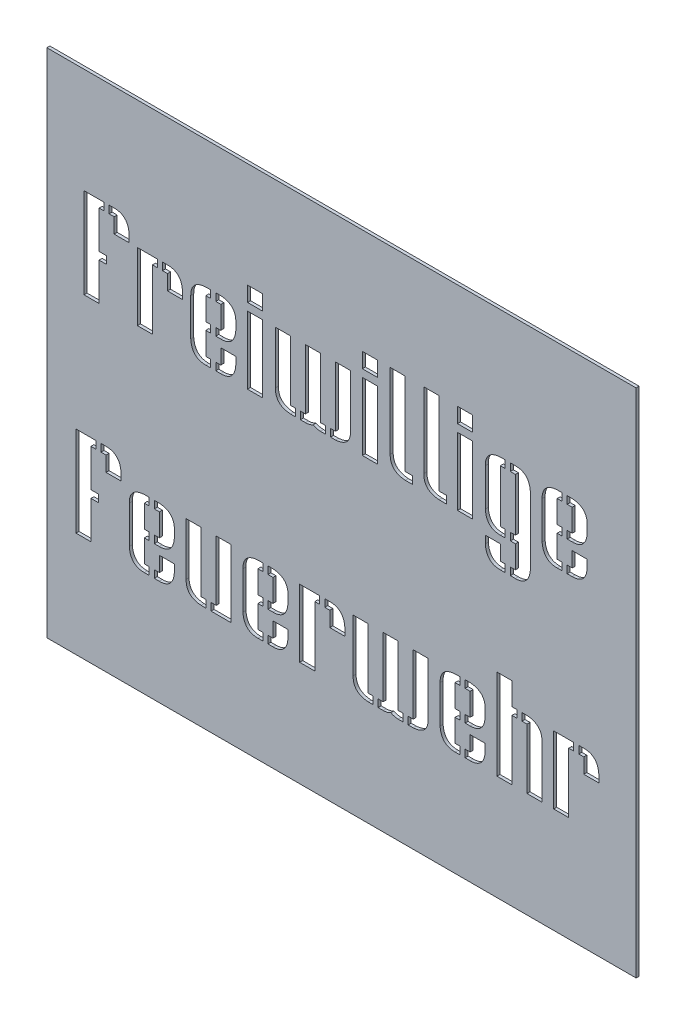
from build123d import *

# Parameters (mm, degrees)
SKIZZE1_W                       = 980
SKIZZE1_H                       = 850
AUFSATZ_LINEAR_AUSTRAGEN1_DEPTH = 5
SKIZZE3_W                       = 24.984930681
SKIZZE3_H                       = 25.015069319
SKIZZE3_H_2                     = 112.477396022
SCHNITT_LINEAR_AUSTRAGEN1_DEPTH = 6


with BuildPart() as part:
    # Skizze1 → Aufsatz-Linear austragen1 (new body)
    with BuildSketch(Plane.XY):
        Rectangle(SKIZZE1_W, SKIZZE1_H)
    extrude(amount=AUFSATZ_LINEAR_AUSTRAGEN1_DEPTH)

    # Skizze3 → Schnitt-Linear austragen1 (cut, through all)
    with BuildSketch(Plane.XY.offset(5)):
        with BuildLine():
            Line((-353.224834237, 212.477396022), (-378.209764919, 212.477396022))
            Line((-378.209764919, 212.477396022), (-378.209764919, 237.492465341))
            Line((-378.209764919, 237.492465341), (-386.558167571, 237.492465341))
            Line((-386.558167571, 237.492465341), (-386.558167571, 250))
            Line((-386.558167571, 250), (-378.209764919, 250))
            add(Edge.make_bspline(
                [(-378.209764919, 250), (-377.264356307, 249.987088662), (-375.428641434, 249.962018512), (-372.760830229, 249.640295999), (-370.252239062, 249.182729456), (-367.919275239, 248.469413134), (-365.738328338, 247.623878238), (-363.760072475, 246.499082287), (-361.920189143, 245.258172926), (-360.254958982, 243.780983696), (-358.806373284, 242.083217389), (-357.440704372, 240.248895349), (-356.349822772, 238.153765192), (-355.333505299, 235.915189224), (-354.575059608, 233.447173634), (-353.927481919, 230.814241232), (-353.485662704, 227.969417176), (-353.31361535, 226.000793851), (-353.224834237, 224.984930681)],
                knots=[0, 0, 0, 0, 1.13484279, 2.203542217, 3.223513397, 4.193209845, 5.129833905, 6.026427552, 6.920093274, 7.791903654, 8.689795538, 9.597364999, 10.531498447, 11.520227857, 12.546744678, 13.62669317, 14.775309137, 16, 16, 16, 16], degree=3))
            Line((-353.224834237, 224.984930681), (-353.224834237, 212.477396022))
        make_face()
        Polygon((-390.717299578, 162.507534659), (-403.224834237, 162.507534659), (-403.224834237, 100), (-428.209764919, 100), (-428.209764919, 250), (-395.087402049, 250), (-395.087402049, 237.492465341), (-403.224834237, 237.492465341), (-403.224834237, 174.984930681), (-390.717299578, 174.984930681), align=None)
        with BuildLine():
            Line((-264.49668475, 174.984930681), (-289.481615431, 174.984930681))
            Line((-289.481615431, 174.984930681), (-289.481615431, 200))
            Line((-289.481615431, 200), (-297.830018083, 200))
            Line((-297.830018083, 200), (-297.830018083, 212.477396022))
            Line((-297.830018083, 212.477396022), (-289.481615431, 212.477396022))
            add(Edge.make_bspline(
                [(-289.481615431, 212.477396022), (-288.536206536, 212.464484925), (-286.700491112, 212.439415245), (-284.032683794, 212.117689421), (-281.524078912, 211.660134558), (-279.191162902, 210.946777517), (-277.010047622, 210.101386017), (-275.03238944, 208.976081069), (-273.19032042, 207.737033081), (-271.538759718, 206.258036056), (-270.057961241, 204.586969036), (-268.722704216, 202.728513519), (-267.627394223, 200.639280766), (-266.599161648, 198.415380853), (-265.843088493, 195.945404349), (-265.203267029, 193.300757314), (-264.758923858, 190.456800572), (-264.58566476, 188.498290064), (-264.49668475, 187.492465341)],
                knots=[0, 0, 0, 0, 1.135590762, 2.204994565, 3.225638006, 4.195973577, 5.133214963, 6.030399554, 6.924654288, 7.797039276, 8.686471432, 9.604459109, 10.539208242, 11.517549339, 12.544742735, 13.6371442, 14.786517217, 16, 16, 16, 16], degree=3))
            Line((-264.49668475, 187.492465341), (-264.49668475, 174.984930681))
        make_face()
        Polygon((-306.359252562, 212.477396022), (-306.359252562, 200), (-314.49668475, 200), (-314.49668475, 100), (-339.481615431, 100), (-339.481615431, 212.477396022), align=None)
        with BuildLine():
            add(Edge.make_bspline(
                [(-175.768535262, 174.984930681), (-175.857515272, 173.979105958), (-176.03077437, 172.02059545), (-176.475117541, 169.176638708), (-177.114939005, 166.531991673), (-177.87101216, 164.062015169), (-178.899244735, 161.838115256), (-179.994554728, 159.748882502), (-181.329811753, 157.890426986), (-182.810610231, 156.219359966), (-184.462170933, 154.740362941), (-186.304239952, 153.501314953), (-188.281898134, 152.376010005), (-190.463013414, 151.530618505), (-192.795929424, 150.817261464), (-195.304534306, 150.359706601), (-197.972341624, 150.037980777), (-199.808057048, 150.012911097), (-200.753465943, 150)],
                knots=[0, 0, 0, 0, 1.213482783, 2.3628558, 3.455257265, 4.482450661, 5.460791758, 6.395540891, 7.313528568, 8.202960724, 9.075345712, 9.969600446, 10.866785037, 11.804026423, 12.774361994, 13.795005435, 14.864409238, 16, 16, 16, 16], degree=3))
            Line((-200.753465943, 150), (-209.101868596, 150))
            Line((-209.101868596, 150), (-209.101868596, 162.507534659))
            Line((-209.101868596, 162.507534659), (-200.753465943, 162.507534659))
            Line((-200.753465943, 162.507534659), (-200.753465943, 200))
            Line((-200.753465943, 200), (-209.101868596, 200))
            Line((-209.101868596, 200), (-209.101868596, 212.477396022))
            Line((-209.101868596, 212.477396022), (-200.753465943, 212.477396022))
            add(Edge.make_bspline(
                [(-200.753465943, 212.477396022), (-199.747224388, 212.379569764), (-197.78726424, 212.189023502), (-194.949361972, 211.699515522), (-192.293143896, 211.083475575), (-189.83836334, 210.272746665), (-187.595262046, 209.267494243), (-185.535997076, 208.120393029), (-183.650101177, 206.829937543), (-181.977282645, 205.342960303), (-180.528755116, 203.667921193), (-179.25905844, 201.848978562), (-178.1459047, 199.872405867), (-177.304382365, 197.701151033), (-176.585200007, 195.390322829), (-176.125632143, 192.901646414), (-175.808076968, 190.253388942), (-175.781930914, 188.427791001), (-175.768535262, 187.492465341)],
                knots=[0, 0, 0, 0, 1.2170612, 2.370595249, 3.465080836, 4.497995561, 5.478203172, 6.420577595, 7.333368485, 8.224497531, 9.107625348, 9.993648539, 10.89254481, 11.831574297, 12.792175775, 13.802890088, 14.874334138, 16, 16, 16, 16], degree=3))
            Line((-175.768535262, 187.492465341), (-175.768535262, 174.984930681))
        make_face()
        with BuildLine():
            add(Edge.make_bspline(
                [(-175.768535262, 124.984930681), (-175.857515272, 123.979105958), (-176.03077437, 122.02059545), (-176.475117541, 119.176638708), (-177.114939005, 116.531991673), (-177.87101216, 114.062015169), (-178.899244735, 111.838115256), (-179.994554728, 109.748882502), (-181.329811753, 107.890426986), (-182.810610231, 106.219359966), (-184.462170933, 104.740362941), (-186.304239952, 103.501314953), (-188.281898134, 102.376010005), (-190.463013414, 101.530618505), (-192.795929424, 100.817261464), (-195.304534306, 100.359706601), (-197.972341624, 100.037980777), (-199.808057048, 100.012911097), (-200.753465943, 100)],
                knots=[0, 0, 0, 0, 1.213482783, 2.3628558, 3.455257265, 4.482450661, 5.460791758, 6.395540891, 7.313528568, 8.202960724, 9.075345712, 9.969600446, 10.866785037, 11.804026423, 12.774361994, 13.795005435, 14.864409238, 16, 16, 16, 16], degree=3))
            Line((-200.753465943, 100), (-209.101868596, 100))
            Line((-209.101868596, 100), (-209.101868596, 112.507534659))
            Line((-209.101868596, 112.507534659), (-200.753465943, 112.507534659))
            Line((-200.753465943, 112.507534659), (-200.753465943, 137.492465341))
            Line((-200.753465943, 137.492465341), (-175.768535262, 137.492465341))
            Line((-175.768535262, 137.492465341), (-175.768535262, 124.984930681))
        make_face()
        with BuildLine():
            Line((-217.631103074, 112.507534659), (-217.631103074, 100))
            Line((-217.631103074, 100), (-225.768535262, 100))
            add(Edge.make_bspline(
                [(-225.768535262, 100), (-226.703860923, 100.013395652), (-228.529458864, 100.039541706), (-231.177716336, 100.357096881), (-233.666392751, 100.816664745), (-235.977220954, 101.535847103), (-238.148475789, 102.377369438), (-240.125048484, 103.490523177), (-241.943991114, 104.760219853), (-243.619030224, 106.208747383), (-245.106007464, 107.881565915), (-246.396462951, 109.767461814), (-247.543564165, 111.826726784), (-248.548816587, 114.069828078), (-249.359545497, 116.524608634), (-249.975585444, 119.18082671), (-250.465093423, 122.018728977), (-250.655639685, 123.978689126), (-250.753465943, 124.984930681)],
                knots=[0, 0, 0, 0, 1.125665862, 2.197109912, 3.207824225, 4.168425703, 5.10745519, 6.006351461, 6.892374652, 7.775502469, 8.666631515, 9.579422405, 10.521796828, 11.502004439, 12.534919164, 13.629404751, 14.7829388, 16, 16, 16, 16], degree=3))
            add(Edge.make_bspline(
                [(-250.753465943, 124.984930681), (-250.718924608, 129.756860402), (-250.647733756, 139.591967695), (-250.624436474, 154.78200338), (-250.652204563, 170.846009577), (-250.71912127, 181.846511377), (-250.753465943, 187.492465341)],
                knots=[0, 0, 0, 0, 0.916113844, 1.888141375, 2.916098848, 4, 4, 4, 4], degree=3))
            add(Edge.make_bspline(
                [(-250.753465943, 187.492465341), (-250.749363561, 188.437455209), (-250.741401492, 190.271529893), (-250.465352405, 192.944500515), (-249.983583033, 195.443485799), (-249.324922934, 197.789723054), (-248.458747096, 199.954427185), (-247.377644487, 201.949110146), (-246.133478766, 203.793484182), (-244.623812606, 205.425414451), (-242.9551528, 206.917860135), (-241.0941433, 208.250024731), (-238.999367953, 209.354729703), (-236.758471007, 210.367635949), (-234.282307445, 211.132058319), (-231.627470011, 211.773937011), (-228.762810472, 212.214599308), (-226.784365647, 212.38824026), (-225.768535262, 212.477396022)],
                knots=[0, 0, 0, 0, 1.132985534, 2.198944301, 3.217534162, 4.182537582, 5.117893198, 6.007496699, 6.899952154, 7.778633815, 8.666276396, 9.582417041, 10.515285418, 11.502675819, 12.527802457, 13.618005963, 14.776967702, 16, 16, 16, 16], degree=3))
            Line((-225.768535262, 212.477396022), (-217.631103074, 212.477396022))
            Line((-217.631103074, 212.477396022), (-217.631103074, 200))
            Line((-217.631103074, 200), (-225.768535262, 200))
            Line((-225.768535262, 200), (-225.768535262, 162.507534659))
            Line((-225.768535262, 162.507534659), (-217.631103074, 162.507534659))
            Line((-217.631103074, 162.507534659), (-217.631103074, 150))
            Line((-217.631103074, 150), (-225.768535262, 150))
            Line((-225.768535262, 150), (-225.768535262, 112.507534659))
            Line((-225.768535262, 112.507534659), (-217.631103074, 112.507534659))
        make_face()
        with Locations((-143.746232671, 237.492465341)):
            Rectangle(SKIZZE3_W, SKIZZE3_H)
        with Locations((-143.746232671, 156.238698011)):
            Rectangle(SKIZZE3_W, SKIZZE3_H_2)
        with BuildLine():
            add(Edge.make_bspline(
                [(15.039180229, 124.984930681), (15.034633091, 124.050018871), (15.025761841, 122.226050345), (14.753583732, 119.572638831), (14.270001076, 117.093640624), (13.60546799, 114.769353998), (12.743052822, 112.614627246), (11.673989121, 110.621067428), (10.399265797, 108.799987602), (8.920036912, 107.144254114), (7.249719366, 105.64575794), (5.361285294, 104.358329772), (3.296563979, 103.201689087), (1.036320144, 102.212077123), (-1.424610254, 101.392903835), (-4.090968859, 100.774709467), (-6.949620266, 100.288911593), (-8.929504683, 100.097994802), (-9.945750452, 100)],
                knots=[0, 0, 0, 0, 1.123083401, 2.191082361, 3.199769231, 4.155016541, 5.092162382, 5.983468542, 6.867714414, 7.757055899, 8.646397384, 9.55735726, 10.497841328, 11.487121546, 12.517964296, 13.610254399, 14.773378468, 16, 16, 16, 16], degree=3))
            Line((-9.945750452, 100), (-18.294153104, 100))
            Line((-18.294153104, 100), (-18.294153104, 112.507534659))
            Line((-18.294153104, 112.507534659), (-9.945750452, 112.507534659))
            Line((-9.945750452, 112.507534659), (-9.945750452, 212.477396022))
            Line((-9.945750452, 212.477396022), (15.039180229, 212.477396022))
            add(Edge.make_bspline(
                [(15.039180229, 212.477396022), (15.005778078, 209.885501903), (14.934961974, 204.390411265), (14.89256771, 195.700200665), (14.807577538, 186.10621538), (14.838173609, 175.617832027), (14.809673213, 164.235396988), (14.898557467, 151.948997922), (14.941590497, 138.768245702), (15.005962625, 129.676497075), (15.039180229, 124.984930681)],
                knots=[0, 0, 0, 0, 0.711024507, 1.507447424, 2.383784558, 3.342776041, 4.384439203, 5.506031864, 6.713050968, 8, 8, 8, 8], degree=3))
        make_face()
        with BuildLine():
            Line((-26.823387583, 112.507534659), (-26.823387583, 100))
            Line((-26.823387583, 100), (-34.960819771, 100))
            add(Edge.make_bspline(
                [(-34.960819771, 100), (-35.917492032, 100.048400133), (-37.896431976, 100.148519013), (-40.925648944, 100.74133863), (-44.067487657, 101.752975203), (-46.149772773, 102.663348323), (-47.227245329, 103.134418324)],
                knots=[0, 0, 0, 0, 0.90044726, 1.862634804, 2.894026413, 4, 4, 4, 4], degree=3))
            add(Edge.make_bspline(
                [(-47.227245329, 103.134418324), (-48.180635487, 102.656432539), (-50.106602653, 101.690841569), (-53.223122243, 100.710423788), (-56.528281851, 100.127793701), (-58.787989454, 100.043293613), (-59.945750452, 100)],
                knots=[0, 0, 0, 0, 0.96593127, 1.95130178, 2.950349641, 4, 4, 4, 4], degree=3))
            Line((-59.945750452, 100), (-68.294153104, 100))
            Line((-68.294153104, 100), (-68.294153104, 112.507534659))
            Line((-68.294153104, 112.507534659), (-59.945750452, 112.507534659))
            Line((-59.945750452, 112.507534659), (-59.945750452, 212.477396022))
            Line((-59.945750452, 212.477396022), (-34.960819771, 212.477396022))
            Line((-34.960819771, 212.477396022), (-34.960819771, 112.507534659))
            Line((-34.960819771, 112.507534659), (-26.823387583, 112.507534659))
        make_face()
        with BuildLine():
            Line((-76.823387583, 112.507534659), (-76.823387583, 100))
            Line((-76.823387583, 100), (-84.960819771, 100))
            add(Edge.make_bspline(
                [(-84.960819771, 100), (-85.97706554, 100.097994802), (-87.956949957, 100.288911593), (-90.815601364, 100.774709467), (-93.481959969, 101.392903835), (-95.942890367, 102.212077123), (-98.203134202, 103.201689087), (-100.267855517, 104.358329772), (-102.156289589, 105.64575794), (-103.826607135, 107.144254114), (-105.30583602, 108.799987602), (-106.580559344, 110.621067428), (-107.649623045, 112.614627246), (-108.512038213, 114.769353998), (-109.176571299, 117.093640624), (-109.660153955, 119.572638831), (-109.932332064, 122.226050345), (-109.941203314, 124.050018871), (-109.945750452, 124.984930681)],
                knots=[0, 0, 0, 0, 1.226621532, 2.389745601, 3.482035704, 4.512878454, 5.502158672, 6.44264274, 7.353602616, 8.242944101, 9.132285586, 10.016531458, 10.907837618, 11.844983459, 12.800230769, 13.808917639, 14.876916599, 16, 16, 16, 16], degree=3))
            Line((-109.945750452, 124.984930681), (-109.945750452, 212.477396022))
            Line((-109.945750452, 212.477396022), (-84.960819771, 212.477396022))
            Line((-84.960819771, 212.477396022), (-84.960819771, 112.507534659))
            Line((-84.960819771, 112.507534659), (-76.823387583, 112.507534659))
        make_face()
        with Locations((47.212176009, 237.492465341)):
            Rectangle(SKIZZE3_W, SKIZZE3_H)
        with Locations((47.212176009, 156.238698011)):
            Rectangle(SKIZZE3_W, SKIZZE3_H_2)
        with BuildLine():
            Line((118.505123568, 100), (105.997588909, 100))
            add(Edge.make_bspline(
                [(105.997588909, 100), (104.98134314, 100.097994802), (103.001458723, 100.288911592), (100.142807316, 100.774709467), (97.476448711, 101.392903835), (95.015518313, 102.212077123), (92.755274477, 103.201689087), (90.690553163, 104.358329772), (88.802119091, 105.64575794), (87.131801545, 107.144254114), (85.65257266, 108.799987602), (84.377849336, 110.621067428), (83.308785635, 112.614627246), (82.446370467, 114.769353998), (81.781837381, 117.093640624), (81.298254725, 119.572638831), (81.026076616, 122.226050345), (81.017205366, 124.050018871), (81.012658228, 124.984930681)],
                knots=[0, 0, 0, 0, 1.226621532, 2.389745601, 3.482035704, 4.512878454, 5.502158672, 6.44264274, 7.353602616, 8.242944101, 9.132285586, 10.016531458, 10.907837618, 11.844983459, 12.800230769, 13.808917639, 14.876916599, 16, 16, 16, 16], degree=3))
            Line((81.012658228, 124.984930681), (81.012658228, 250))
            Line((81.012658228, 250), (105.997588909, 250))
            Line((105.997588909, 250), (105.997588909, 112.507534659))
            Line((105.997588909, 112.507534659), (118.505123568, 112.507534659))
            Line((118.505123568, 112.507534659), (118.505123568, 100))
        make_face()
        with BuildLine():
            Line((174.442435202, 100), (161.934900542, 100))
            add(Edge.make_bspline(
                [(161.934900542, 100), (160.918654773, 100.097994802), (158.938770356, 100.288911592), (156.080118949, 100.774709467), (153.413760344, 101.392903835), (150.952829946, 102.212077123), (148.692586111, 103.201689087), (146.627864797, 104.358329772), (144.739430724, 105.64575794), (143.069113178, 107.144254114), (141.589884294, 108.799987602), (140.315160969, 110.621067428), (139.246097269, 112.614627246), (138.3836821, 114.769353998), (137.719149014, 117.093640624), (137.235566359, 119.572638831), (136.96338825, 122.226050345), (136.954516999, 124.050018871), (136.949969861, 124.984930681)],
                knots=[0, 0, 0, 0, 1.226621532, 2.389745601, 3.482035704, 4.512878454, 5.502158672, 6.44264274, 7.353602616, 8.242944101, 9.132285586, 10.016531458, 10.907837618, 11.844983459, 12.800230769, 13.808917639, 14.876916599, 16, 16, 16, 16], degree=3))
            Line((136.949969861, 124.984930681), (136.949969861, 250))
            Line((136.949969861, 250), (161.934900542, 250))
            Line((161.934900542, 250), (161.934900542, 112.507534659))
            Line((161.934900542, 112.507534659), (174.442435202, 112.507534659))
            Line((174.442435202, 112.507534659), (174.442435202, 100))
        make_face()
        with Locations((205.379746836, 237.492465341)):
            Rectangle(SKIZZE3_W, SKIZZE3_H)
        with Locations((205.379746836, 156.238698011)):
            Rectangle(SKIZZE3_W, SKIZZE3_H_2)
        with BuildLine():
            add(Edge.make_bspline(
                [(314.165159735, 75.015069319), (314.067580574, 73.998775904), (313.878420522, 72.02866145), (313.391305247, 69.189938381), (312.767299766, 66.545451187), (311.953978664, 64.09284805), (310.961752589, 61.834172705), (309.816471572, 59.771632157), (308.509182792, 57.907032204), (307.021836782, 56.239467879), (305.366129141, 54.758246074), (303.535389064, 53.492091218), (301.560552214, 52.376926059), (299.388807862, 51.535970956), (297.078117067, 50.816629374), (294.589401268, 50.357107146), (291.941155057, 50.039538922), (290.115555528, 50.013394709), (289.180229054, 50)],
                knots=[0, 0, 0, 0, 1.228364586, 2.38122061, 3.463306211, 4.495613809, 5.486299815, 6.428120329, 7.330466038, 8.221071296, 9.111676553, 9.997178957, 10.895546873, 11.834024418, 12.794061272, 13.804181507, 14.874995783, 16, 16, 16, 16], degree=3))
            Line((289.180229054, 50), (280.831826401, 50))
            Line((280.831826401, 50), (280.831826401, 62.507534659))
            Line((280.831826401, 62.507534659), (289.180229054, 62.507534659))
            Line((289.180229054, 62.507534659), (289.180229054, 100))
            Line((289.180229054, 100), (280.831826401, 100))
            Line((280.831826401, 100), (280.831826401, 112.507534659))
            Line((280.831826401, 112.507534659), (289.180229054, 112.507534659))
            Line((289.180229054, 112.507534659), (289.180229054, 200))
            Line((289.180229054, 200), (280.831826401, 200))
            Line((280.831826401, 200), (280.831826401, 212.477396022))
            Line((280.831826401, 212.477396022), (289.180229054, 212.477396022))
            add(Edge.make_bspline(
                [(289.180229054, 212.477396022), (290.115554714, 212.46400037), (291.941152655, 212.437854316), (294.589410127, 212.120299141), (297.078086542, 211.660731277), (299.388914746, 210.941548919), (301.560169581, 210.100026584), (303.536742275, 208.986872844), (305.355684906, 207.717176168), (307.030724016, 206.268648639), (308.517701256, 204.595830107), (309.808156742, 202.709934208), (310.955257956, 200.650669238), (311.960510378, 198.407567944), (312.771239288, 195.952787388), (313.387279235, 193.296569312), (313.876787215, 190.458667044), (314.067333477, 188.498706896), (314.165159735, 187.492465341)],
                knots=[0, 0, 0, 0, 1.125665862, 2.197109912, 3.207824225, 4.168425703, 5.10745519, 6.006351461, 6.892374652, 7.775502469, 8.666631515, 9.579422405, 10.521796828, 11.502004439, 12.534919164, 13.629404751, 14.7829388, 16, 16, 16, 16], degree=3))
            Line((314.165159735, 187.492465341), (314.165159735, 75.015069319))
        make_face()
        with BuildLine():
            Line((272.302591923, 112.507534659), (272.302591923, 100))
            Line((272.302591923, 100), (264.165159735, 100))
            add(Edge.make_bspline(
                [(264.165159735, 100), (263.229834074, 100.013395652), (261.404236133, 100.039541706), (258.755978661, 100.357096881), (256.267302246, 100.816664745), (253.956474043, 101.535847103), (251.785219208, 102.377369438), (249.808646513, 103.490523177), (247.989703883, 104.760219853), (246.314664773, 106.208747383), (244.827687533, 107.881565915), (243.537232046, 109.767461814), (242.390130832, 111.826726784), (241.38487841, 114.069828078), (240.5741495, 116.524608634), (239.958109553, 119.18082671), (239.468601574, 122.018728977), (239.278055312, 123.978689126), (239.180229054, 124.984930681)],
                knots=[0, 0, 0, 0, 1.125665862, 2.197109912, 3.207824225, 4.168425703, 5.10745519, 6.006351461, 6.892374652, 7.775502469, 8.666631515, 9.579422405, 10.521796828, 11.502004439, 12.534919164, 13.629404751, 14.7829388, 16, 16, 16, 16], degree=3))
            add(Edge.make_bspline(
                [(239.180229054, 124.984930681), (239.2365147, 129.756825516), (239.352519542, 139.591711298), (239.412520462, 154.782011329), (239.344305594, 170.846199928), (239.235879012, 181.846539531), (239.180229054, 187.492465341)],
                knots=[0, 0, 0, 0, 0.91613004, 1.888146034, 2.916090662, 4, 4, 4, 4], degree=3))
            add(Edge.make_bspline(
                [(239.180229054, 187.492465341), (239.184331436, 188.437455209), (239.192293505, 190.271529893), (239.468342592, 192.944500515), (239.950111964, 195.443485799), (240.608772063, 197.789723054), (241.474947901, 199.954427185), (242.55605051, 201.949110146), (243.800216231, 203.793484182), (245.309882391, 205.425414451), (246.978542197, 206.917860135), (248.839551697, 208.250024731), (250.934327044, 209.354729703), (253.17522399, 210.367635949), (255.651387552, 211.132058319), (258.306224986, 211.773937011), (261.170884525, 212.214599308), (263.14932935, 212.38824026), (264.165159735, 212.477396022)],
                knots=[0, 0, 0, 0, 1.132985534, 2.198944301, 3.217534162, 4.182537582, 5.117893198, 6.007496699, 6.899952154, 7.778633815, 8.666276396, 9.582417041, 10.515285418, 11.502675819, 12.527802457, 13.618005963, 14.776967702, 16, 16, 16, 16], degree=3))
            Line((264.165159735, 212.477396022), (272.302591923, 212.477396022))
            Line((272.302591923, 212.477396022), (272.302591923, 200))
            Line((272.302591923, 200), (264.165159735, 200))
            Line((264.165159735, 200), (264.165159735, 112.507534659))
            Line((264.165159735, 112.507534659), (272.302591923, 112.507534659))
        make_face()
        with BuildLine():
            Line((272.302591923, 62.507534659), (272.302591923, 50))
            Line((272.302591923, 50), (264.165159735, 50))
            add(Edge.make_bspline(
                [(264.165159735, 50), (263.22983326, 50.013394709), (261.404233731, 50.039538922), (258.75598752, 50.357107146), (256.267271721, 50.816629374), (253.956580927, 51.535970956), (251.784836574, 52.376926059), (249.809999725, 53.492091218), (247.979259648, 54.758246074), (246.323552006, 56.239467879), (244.836205997, 57.907032204), (243.528917216, 59.771632157), (242.383636199, 61.834172705), (241.391410124, 64.09284805), (240.578089023, 66.545451187), (239.954083541, 69.189938381), (239.466968267, 72.02866145), (239.277808215, 73.998775904), (239.180229054, 75.015069319)],
                knots=[0, 0, 0, 0, 1.125004217, 2.195818493, 3.205938728, 4.165975582, 5.104453127, 6.002821043, 6.888323447, 7.778928704, 8.669533962, 9.571879671, 10.513700185, 11.504386191, 12.536693789, 13.61877939, 14.771635414, 16, 16, 16, 16], degree=3))
            Line((239.180229054, 75.015069319), (239.180229054, 87.492465341))
            Line((239.180229054, 87.492465341), (264.165159735, 87.492465341))
            Line((264.165159735, 87.492465341), (264.165159735, 62.507534659))
            Line((264.165159735, 62.507534659), (272.302591923, 62.507534659))
        make_face()
        with BuildLine():
            add(Edge.make_bspline(
                [(408.679927667, 174.984930681), (408.590947657, 173.979105958), (408.417688559, 172.02059545), (407.973345388, 169.176638708), (407.333523925, 166.531991673), (406.577450769, 164.062015169), (405.549218195, 161.838115256), (404.453908201, 159.748882502), (403.118651176, 157.890426986), (401.637852699, 156.219359966), (399.986291997, 154.740362941), (398.144222977, 153.501314953), (396.166564795, 152.376010005), (393.985449515, 151.530618505), (391.652533505, 150.817261464), (389.143928623, 150.359706601), (386.476121305, 150.037980777), (384.640405881, 150.012911097), (383.694996986, 150)],
                knots=[0, 0, 0, 0, 1.213482783, 2.3628558, 3.455257265, 4.482450661, 5.460791758, 6.395540891, 7.313528568, 8.202960724, 9.075345712, 9.969600446, 10.866785037, 11.804026423, 12.774361994, 13.795005435, 14.864409238, 16, 16, 16, 16], degree=3))
            Line((383.694996986, 150), (375.346594334, 150))
            Line((375.346594334, 150), (375.346594334, 162.507534659))
            Line((375.346594334, 162.507534659), (383.694996986, 162.507534659))
            Line((383.694996986, 162.507534659), (383.694996986, 200))
            Line((383.694996986, 200), (375.346594334, 200))
            Line((375.346594334, 200), (375.346594334, 212.477396022))
            Line((375.346594334, 212.477396022), (383.694996986, 212.477396022))
            add(Edge.make_bspline(
                [(383.694996986, 212.477396022), (384.701238541, 212.379569764), (386.66119869, 212.189023502), (389.499100957, 211.699515522), (392.155319034, 211.083475575), (394.610099589, 210.272746665), (396.853200883, 209.267494243), (398.912465854, 208.120393029), (400.798361753, 206.829937543), (402.471180285, 205.342960303), (403.919707814, 203.667921193), (405.18940449, 201.848978562), (406.30255823, 199.872405867), (407.144080564, 197.701151033), (407.863262922, 195.390322829), (408.322830786, 192.901646414), (408.640385962, 190.253388942), (408.666532015, 188.427791001), (408.679927667, 187.492465341)],
                knots=[0, 0, 0, 0, 1.2170612, 2.370595249, 3.465080836, 4.497995561, 5.478203172, 6.420577595, 7.333368485, 8.224497531, 9.107625348, 9.993648539, 10.89254481, 11.831574297, 12.792175775, 13.802890088, 14.874334138, 16, 16, 16, 16], degree=3))
            Line((408.679927667, 187.492465341), (408.679927667, 174.984930681))
        make_face()
        with BuildLine():
            add(Edge.make_bspline(
                [(408.679927667, 124.984930681), (408.590947657, 123.979105958), (408.417688559, 122.02059545), (407.973345388, 119.176638708), (407.333523925, 116.531991673), (406.577450769, 114.062015169), (405.549218195, 111.838115256), (404.453908201, 109.748882502), (403.118651176, 107.890426986), (401.637852699, 106.219359966), (399.986291997, 104.740362941), (398.144222977, 103.501314953), (396.166564795, 102.376010005), (393.985449515, 101.530618505), (391.652533505, 100.817261464), (389.143928623, 100.359706601), (386.476121305, 100.037980777), (384.640405881, 100.012911097), (383.694996986, 100)],
                knots=[0, 0, 0, 0, 1.213482783, 2.3628558, 3.455257265, 4.482450661, 5.460791758, 6.395540891, 7.313528568, 8.202960724, 9.075345712, 9.969600446, 10.866785037, 11.804026423, 12.774361994, 13.795005435, 14.864409238, 16, 16, 16, 16], degree=3))
            Line((383.694996986, 100), (375.346594334, 100))
            Line((375.346594334, 100), (375.346594334, 112.507534659))
            Line((375.346594334, 112.507534659), (383.694996986, 112.507534659))
            Line((383.694996986, 112.507534659), (383.694996986, 137.492465341))
            Line((383.694996986, 137.492465341), (408.679927667, 137.492465341))
            Line((408.679927667, 137.492465341), (408.679927667, 124.984930681))
        make_face()
        with BuildLine():
            Line((366.817359855, 112.507534659), (366.817359855, 100))
            Line((366.817359855, 100), (358.679927667, 100))
            add(Edge.make_bspline(
                [(358.679927667, 100), (357.744602007, 100.013395652), (355.919004066, 100.039541706), (353.270746594, 100.357096881), (350.782070179, 100.816664745), (348.471241975, 101.535847103), (346.29998714, 102.377369438), (344.323414446, 103.490523177), (342.504471815, 104.760219853), (340.829432705, 106.208747383), (339.342455465, 107.881565915), (338.051999979, 109.767461814), (336.904898765, 111.826726784), (335.899646343, 114.069828078), (335.088917433, 116.524608634), (334.472877486, 119.18082671), (333.983369506, 122.018728977), (333.792823244, 123.978689126), (333.694996986, 124.984930681)],
                knots=[0, 0, 0, 0, 1.125665862, 2.197109912, 3.207824225, 4.168425703, 5.10745519, 6.006351461, 6.892374652, 7.775502469, 8.666631515, 9.579422405, 10.521796828, 11.502004439, 12.534919164, 13.629404751, 14.7829388, 16, 16, 16, 16], degree=3))
            add(Edge.make_bspline(
                [(333.694996986, 124.984930681), (333.729538322, 129.756860402), (333.800729173, 139.591967695), (333.824026456, 154.78200338), (333.796258366, 170.846009577), (333.72934166, 181.846511377), (333.694996986, 187.492465341)],
                knots=[0, 0, 0, 0, 0.916113844, 1.888141375, 2.916098848, 4, 4, 4, 4], degree=3))
            add(Edge.make_bspline(
                [(333.694996986, 187.492465341), (333.699099368, 188.437455209), (333.707061438, 190.271529893), (333.983110524, 192.944500515), (334.464879897, 195.443485799), (335.123539995, 197.789723054), (335.989715834, 199.954427185), (337.070818443, 201.949110146), (338.314984164, 203.793484182), (339.824650323, 205.425414451), (341.493310129, 206.917860135), (343.35431963, 208.250024731), (345.449094977, 209.354729703), (347.689991923, 210.367635949), (350.166155485, 211.132058319), (352.820992918, 211.773937011), (355.685652457, 212.214599308), (357.664097282, 212.38824026), (358.679927667, 212.477396022)],
                knots=[0, 0, 0, 0, 1.132985534, 2.198944301, 3.217534162, 4.182537582, 5.117893198, 6.007496699, 6.899952154, 7.778633815, 8.666276396, 9.582417041, 10.515285418, 11.502675819, 12.527802457, 13.618005963, 14.776967702, 16, 16, 16, 16], degree=3))
            Line((358.679927667, 212.477396022), (366.817359855, 212.477396022))
            Line((366.817359855, 212.477396022), (366.817359855, 200))
            Line((366.817359855, 200), (358.679927667, 200))
            Line((358.679927667, 200), (358.679927667, 162.507534659))
            Line((358.679927667, 162.507534659), (366.817359855, 162.507534659))
            Line((366.817359855, 162.507534659), (366.817359855, 150))
            Line((366.817359855, 150), (358.679927667, 150))
            Line((358.679927667, 150), (358.679927667, 112.507534659))
            Line((358.679927667, 112.507534659), (366.817359855, 112.507534659))
        make_face()
        with BuildLine():
            Line((-366.726943942, -137.522603978), (-391.711874623, -137.522603978))
            Line((-391.711874623, -137.522603978), (-391.711874623, -112.507534659))
            Line((-391.711874623, -112.507534659), (-400.060277275, -112.507534659))
            Line((-400.060277275, -112.507534659), (-400.060277275, -100))
            Line((-400.060277275, -100), (-391.711874623, -100))
            add(Edge.make_bspline(
                [(-391.711874623, -100), (-390.766466012, -100.012911338), (-388.930751138, -100.037981488), (-386.262939933, -100.359704001), (-383.754348767, -100.817270544), (-381.421384943, -101.530586866), (-379.240438043, -102.376121762), (-377.26218218, -103.500917713), (-375.422298847, -104.741827074), (-373.757068687, -106.219016304), (-372.308482989, -107.916782611), (-370.942814076, -109.751104651), (-369.851932476, -111.846234808), (-368.835615003, -114.084810776), (-368.077169312, -116.552826366), (-367.429591623, -119.185758768), (-366.987772409, -122.030582824), (-366.815725055, -123.999206149), (-366.726943942, -125.015069319)],
                knots=[0, 0, 0, 0, 1.13484279, 2.203542217, 3.223513397, 4.193209845, 5.129833905, 6.026427552, 6.920093274, 7.791903654, 8.689795538, 9.597364999, 10.531498447, 11.520227857, 12.546744678, 13.62669317, 14.775309137, 16, 16, 16, 16], degree=3))
            Line((-366.726943942, -125.015069319), (-366.726943942, -137.522603978))
        make_face()
        Polygon((-404.219409283, -187.492465341), (-416.726943942, -187.492465341), (-416.726943942, -250), (-441.711874623, -250), (-441.711874623, -100), (-408.589511754, -100), (-408.589511754, -112.507534659), (-416.726943942, -112.507534659), (-416.726943942, -175.015069319), (-404.219409283, -175.015069319), align=None)
        with BuildLine():
            add(Edge.make_bspline(
                [(-277.998794454, -175.015069319), (-278.087774464, -176.020894042), (-278.261033562, -177.97940455), (-278.705376734, -180.823361292), (-279.345198197, -183.468008327), (-280.101271353, -185.937984831), (-281.129503927, -188.161884744), (-282.22481392, -190.251117498), (-283.560070946, -192.109573014), (-285.040869423, -193.780640034), (-286.692430125, -195.259637059), (-288.534499145, -196.498685047), (-290.512157326, -197.623989995), (-292.693272607, -198.469381495), (-295.026188617, -199.182738536), (-297.534793499, -199.640293399), (-300.202600816, -199.962019223), (-302.03831624, -199.987088903), (-302.983725136, -200)],
                knots=[0, 0, 0, 0, 1.213482783, 2.3628558, 3.455257265, 4.482450661, 5.460791758, 6.395540891, 7.313528568, 8.202960724, 9.075345712, 9.969600446, 10.866785037, 11.804026423, 12.774361994, 13.795005435, 14.864409238, 16, 16, 16, 16], degree=3))
            Line((-302.983725136, -200), (-311.332127788, -200))
            Line((-311.332127788, -200), (-311.332127788, -187.492465341))
            Line((-311.332127788, -187.492465341), (-302.983725136, -187.492465341))
            Line((-302.983725136, -187.492465341), (-302.983725136, -150))
            Line((-302.983725136, -150), (-311.332127788, -150))
            Line((-311.332127788, -150), (-311.332127788, -137.522603978))
            Line((-311.332127788, -137.522603978), (-302.983725136, -137.522603978))
            add(Edge.make_bspline(
                [(-302.983725136, -137.522603978), (-301.977483581, -137.620430236), (-300.017523432, -137.810976498), (-297.179621164, -138.300484478), (-294.523403088, -138.916524425), (-292.068622532, -139.727253335), (-289.825521239, -140.732505757), (-287.766256268, -141.879606971), (-285.880360369, -143.170062457), (-284.207541837, -144.657039697), (-282.759014308, -146.332078807), (-281.489317632, -148.151021438), (-280.376163892, -150.127594133), (-279.534641558, -152.298848967), (-278.8154592, -154.609677171), (-278.355891336, -157.098353586), (-278.03833616, -159.746611058), (-278.012190107, -161.572208999), (-277.998794454, -162.507534659)],
                knots=[0, 0, 0, 0, 1.2170612, 2.370595249, 3.465080836, 4.497995561, 5.478203172, 6.420577595, 7.333368485, 8.224497531, 9.107625348, 9.993648539, 10.89254481, 11.831574297, 12.792175775, 13.802890088, 14.874334138, 16, 16, 16, 16], degree=3))
            Line((-277.998794454, -162.507534659), (-277.998794454, -175.015069319))
        make_face()
        with BuildLine():
            add(Edge.make_bspline(
                [(-277.998794454, -225.015069319), (-278.087774464, -226.020894042), (-278.261033562, -227.97940455), (-278.705376734, -230.823361292), (-279.345198197, -233.468008327), (-280.101271353, -235.937984831), (-281.129503927, -238.161884744), (-282.22481392, -240.251117498), (-283.560070946, -242.109573014), (-285.040869423, -243.780640034), (-286.692430125, -245.259637059), (-288.534499145, -246.498685047), (-290.512157326, -247.623989995), (-292.693272607, -248.469381495), (-295.026188617, -249.182738536), (-297.534793499, -249.640293399), (-300.202600816, -249.962019223), (-302.03831624, -249.987088903), (-302.983725136, -250)],
                knots=[0, 0, 0, 0, 1.213482783, 2.3628558, 3.455257265, 4.482450661, 5.460791758, 6.395540891, 7.313528568, 8.202960724, 9.075345712, 9.969600446, 10.866785037, 11.804026423, 12.774361994, 13.795005435, 14.864409238, 16, 16, 16, 16], degree=3))
            Line((-302.983725136, -250), (-311.332127788, -250))
            Line((-311.332127788, -250), (-311.332127788, -237.492465341))
            Line((-311.332127788, -237.492465341), (-302.983725136, -237.492465341))
            Line((-302.983725136, -237.492465341), (-302.983725136, -212.507534659))
            Line((-302.983725136, -212.507534659), (-277.998794454, -212.507534659))
            Line((-277.998794454, -212.507534659), (-277.998794454, -225.015069319))
        make_face()
        with BuildLine():
            Line((-319.861362266, -237.492465341), (-319.861362266, -250))
            Line((-319.861362266, -250), (-327.998794454, -250))
            add(Edge.make_bspline(
                [(-327.998794454, -250), (-328.934120115, -249.986604348), (-330.759718056, -249.960458294), (-333.407975528, -249.642903119), (-335.896651943, -249.183335255), (-338.207480147, -248.464152897), (-340.378734981, -247.622630562), (-342.355307676, -246.509476823), (-344.174250307, -245.239780147), (-345.849289417, -243.791252617), (-347.336266657, -242.118434085), (-348.626722143, -240.232538186), (-349.773823357, -238.173273216), (-350.779075779, -235.930171922), (-351.589804689, -233.475391366), (-352.205844636, -230.81917329), (-352.695352616, -227.981271023), (-352.885898878, -226.021310874), (-352.983725136, -225.015069319)],
                knots=[0, 0, 0, 0, 1.125665862, 2.197109912, 3.207824225, 4.168425703, 5.10745519, 6.006351461, 6.892374652, 7.775502469, 8.666631515, 9.579422405, 10.521796828, 11.502004439, 12.534919164, 13.629404751, 14.7829388, 16, 16, 16, 16], degree=3))
            add(Edge.make_bspline(
                [(-352.983725136, -225.015069319), (-352.9491838, -220.243139598), (-352.877992949, -210.408032305), (-352.854695666, -195.21799662), (-352.882463755, -179.153990423), (-352.949380462, -168.153488623), (-352.983725136, -162.507534659)],
                knots=[0, 0, 0, 0, 0.916113844, 1.888141375, 2.916098848, 4, 4, 4, 4], degree=3))
            add(Edge.make_bspline(
                [(-352.983725136, -162.507534659), (-352.979622754, -161.562544791), (-352.971660684, -159.728470107), (-352.695611597, -157.055499485), (-352.213842225, -154.556514201), (-351.555182127, -152.210276946), (-350.689006288, -150.045572815), (-349.607903679, -148.050889854), (-348.363737958, -146.206515818), (-346.854071799, -144.574585549), (-345.185411993, -143.082139865), (-343.324402492, -141.749975269), (-341.229627145, -140.645270297), (-338.988730199, -139.632364051), (-336.512566637, -138.867941681), (-333.857729204, -138.226062989), (-330.993069664, -137.785400692), (-329.01462484, -137.61175974), (-327.998794454, -137.522603978)],
                knots=[0, 0, 0, 0, 1.132985534, 2.198944301, 3.217534162, 4.182537582, 5.117893198, 6.007496699, 6.899952154, 7.778633815, 8.666276396, 9.582417041, 10.515285418, 11.502675819, 12.527802457, 13.618005963, 14.776967702, 16, 16, 16, 16], degree=3))
            Line((-327.998794454, -137.522603978), (-319.861362266, -137.522603978))
            Line((-319.861362266, -137.522603978), (-319.861362266, -150))
            Line((-319.861362266, -150), (-327.998794454, -150))
            Line((-327.998794454, -150), (-327.998794454, -187.492465341))
            Line((-327.998794454, -187.492465341), (-319.861362266, -187.492465341))
            Line((-319.861362266, -187.492465341), (-319.861362266, -200))
            Line((-319.861362266, -200), (-327.998794454, -200))
            Line((-327.998794454, -200), (-327.998794454, -237.492465341))
            Line((-327.998794454, -237.492465341), (-319.861362266, -237.492465341))
        make_face()
        Polygon((-183.484026522, -250), (-216.817359855, -250), (-216.817359855, -237.492465341), (-208.468957203, -237.492465341), (-208.468957203, -137.522603978), (-183.484026522, -137.522603978), align=None)
        with BuildLine():
            Line((-225.346594334, -237.492465341), (-225.346594334, -250))
            Line((-225.346594334, -250), (-233.484026522, -250))
            add(Edge.make_bspline(
                [(-233.484026522, -250), (-234.500272291, -249.902005198), (-236.480156708, -249.711088407), (-239.338808115, -249.225290533), (-242.00516672, -248.607096165), (-244.466097118, -247.787922877), (-246.726340954, -246.798310913), (-248.791062268, -245.641670228), (-250.67949634, -244.35424206), (-252.349813886, -242.855745886), (-253.829042771, -241.200012398), (-255.103766095, -239.378932572), (-256.172829796, -237.385372754), (-257.035244964, -235.230646002), (-257.69977805, -232.906359376), (-258.183360706, -230.427361169), (-258.455538815, -227.773949655), (-258.464410065, -225.949981129), (-258.468957203, -225.015069319)],
                knots=[0, 0, 0, 0, 1.226621532, 2.389745601, 3.482035704, 4.512878454, 5.502158672, 6.44264274, 7.353602616, 8.242944101, 9.132285586, 10.016531458, 10.907837618, 11.844983459, 12.800230769, 13.808917639, 14.876916599, 16, 16, 16, 16], degree=3))
            Line((-258.468957203, -225.015069319), (-258.468957203, -137.522603978))
            Line((-258.468957203, -137.522603978), (-233.484026522, -137.522603978))
            Line((-233.484026522, -137.522603978), (-233.484026522, -237.492465341))
            Line((-233.484026522, -237.492465341), (-225.346594334, -237.492465341))
        make_face()
        with BuildLine():
            add(Edge.make_bspline(
                [(-88.96925859, -175.015069319), (-89.058238599, -176.020894042), (-89.231497697, -177.97940455), (-89.675840869, -180.823361292), (-90.315662332, -183.468008327), (-91.071735488, -185.937984831), (-92.099968062, -188.161884744), (-93.195278056, -190.251117498), (-94.530535081, -192.109573014), (-96.011333558, -193.780640034), (-97.66289426, -195.259637059), (-99.50496328, -196.498685047), (-101.482621461, -197.623989995), (-103.663736742, -198.469381495), (-105.996652752, -199.182738536), (-108.505257634, -199.640293399), (-111.173064951, -199.962019223), (-113.008780375, -199.987088903), (-113.954189271, -200)],
                knots=[0, 0, 0, 0, 1.213482783, 2.3628558, 3.455257265, 4.482450661, 5.460791758, 6.395540891, 7.313528568, 8.202960724, 9.075345712, 9.969600446, 10.866785037, 11.804026423, 12.774361994, 13.795005435, 14.864409238, 16, 16, 16, 16], degree=3))
            Line((-113.954189271, -200), (-122.302591923, -200))
            Line((-122.302591923, -200), (-122.302591923, -187.492465341))
            Line((-122.302591923, -187.492465341), (-113.954189271, -187.492465341))
            Line((-113.954189271, -187.492465341), (-113.954189271, -150))
            Line((-113.954189271, -150), (-122.302591923, -150))
            Line((-122.302591923, -150), (-122.302591923, -137.522603978))
            Line((-122.302591923, -137.522603978), (-113.954189271, -137.522603978))
            add(Edge.make_bspline(
                [(-113.954189271, -137.522603978), (-112.947947716, -137.620430236), (-110.987987567, -137.810976498), (-108.150085299, -138.300484478), (-105.493867223, -138.916524425), (-103.039086667, -139.727253335), (-100.795985374, -140.732505757), (-98.736720403, -141.879606971), (-96.850824504, -143.170062457), (-95.178005972, -144.657039697), (-93.729478443, -146.332078807), (-92.459781767, -148.151021438), (-91.346628027, -150.127594133), (-90.505105693, -152.298848967), (-89.785923335, -154.609677171), (-89.326355471, -157.098353586), (-89.008800295, -159.746611058), (-88.982654242, -161.572208999), (-88.96925859, -162.507534659)],
                knots=[0, 0, 0, 0, 1.2170612, 2.370595249, 3.465080836, 4.497995561, 5.478203172, 6.420577595, 7.333368485, 8.224497531, 9.107625348, 9.993648539, 10.89254481, 11.831574297, 12.792175775, 13.802890088, 14.874334138, 16, 16, 16, 16], degree=3))
            Line((-88.96925859, -162.507534659), (-88.96925859, -175.015069319))
        make_face()
        with BuildLine():
            add(Edge.make_bspline(
                [(-88.96925859, -225.015069319), (-89.058238599, -226.020894042), (-89.231497697, -227.97940455), (-89.675840869, -230.823361292), (-90.315662332, -233.468008327), (-91.071735488, -235.937984831), (-92.099968062, -238.161884744), (-93.195278056, -240.251117498), (-94.530535081, -242.109573014), (-96.011333558, -243.780640034), (-97.66289426, -245.259637059), (-99.50496328, -246.498685047), (-101.482621461, -247.623989995), (-103.663736742, -248.469381495), (-105.996652752, -249.182738536), (-108.505257634, -249.640293399), (-111.173064951, -249.962019223), (-113.008780375, -249.987088903), (-113.954189271, -250)],
                knots=[0, 0, 0, 0, 1.213482783, 2.3628558, 3.455257265, 4.482450661, 5.460791758, 6.395540891, 7.313528568, 8.202960724, 9.075345712, 9.969600446, 10.866785037, 11.804026423, 12.774361994, 13.795005435, 14.864409238, 16, 16, 16, 16], degree=3))
            Line((-113.954189271, -250), (-122.302591923, -250))
            Line((-122.302591923, -250), (-122.302591923, -237.492465341))
            Line((-122.302591923, -237.492465341), (-113.954189271, -237.492465341))
            Line((-113.954189271, -237.492465341), (-113.954189271, -212.507534659))
            Line((-113.954189271, -212.507534659), (-88.96925859, -212.507534659))
            Line((-88.96925859, -212.507534659), (-88.96925859, -225.015069319))
        make_face()
        with BuildLine():
            Line((-130.831826401, -237.492465341), (-130.831826401, -250))
            Line((-130.831826401, -250), (-138.96925859, -250))
            add(Edge.make_bspline(
                [(-138.96925859, -250), (-139.90458425, -249.986604348), (-141.730182191, -249.960458294), (-144.378439663, -249.642903119), (-146.867116078, -249.183335255), (-149.177944282, -248.464152897), (-151.349199116, -247.622630562), (-153.325771811, -246.509476823), (-155.144714442, -245.239780147), (-156.819753552, -243.791252617), (-158.306730792, -242.118434085), (-159.597186278, -240.232538186), (-160.744287492, -238.173273216), (-161.749539914, -235.930171922), (-162.560268824, -233.475391366), (-163.176308771, -230.81917329), (-163.665816751, -227.981271023), (-163.856363013, -226.021310874), (-163.954189271, -225.015069319)],
                knots=[0, 0, 0, 0, 1.125665862, 2.197109912, 3.207824225, 4.168425703, 5.10745519, 6.006351461, 6.892374652, 7.775502469, 8.666631515, 9.579422405, 10.521796828, 11.502004439, 12.534919164, 13.629404751, 14.7829388, 16, 16, 16, 16], degree=3))
            add(Edge.make_bspline(
                [(-163.954189271, -225.015069319), (-163.919647935, -220.243139598), (-163.848457084, -210.408032305), (-163.825159801, -195.21799662), (-163.85292789, -179.153990423), (-163.919844597, -168.153488623), (-163.954189271, -162.507534659)],
                knots=[0, 0, 0, 0, 0.916113844, 1.888141375, 2.916098848, 4, 4, 4, 4], degree=3))
            add(Edge.make_bspline(
                [(-163.954189271, -162.507534659), (-163.950086889, -161.562544791), (-163.942124819, -159.728470107), (-163.666075732, -157.055499485), (-163.18430636, -154.556514201), (-162.525646262, -152.210276946), (-161.659470423, -150.045572815), (-160.578367814, -148.050889854), (-159.334202093, -146.206515818), (-157.824535934, -144.574585549), (-156.155876128, -143.082139865), (-154.294866627, -141.749975269), (-152.20009128, -140.645270297), (-149.959194334, -139.632364051), (-147.483030772, -138.867941681), (-144.828193339, -138.226062989), (-141.963533799, -137.785400692), (-139.985088975, -137.61175974), (-138.96925859, -137.522603978)],
                knots=[0, 0, 0, 0, 1.132985534, 2.198944301, 3.217534162, 4.182537582, 5.117893198, 6.007496699, 6.899952154, 7.778633815, 8.666276396, 9.582417041, 10.515285418, 11.502675819, 12.527802457, 13.618005963, 14.776967702, 16, 16, 16, 16], degree=3))
            Line((-138.96925859, -137.522603978), (-130.831826401, -137.522603978))
            Line((-130.831826401, -137.522603978), (-130.831826401, -150))
            Line((-130.831826401, -150), (-138.96925859, -150))
            Line((-138.96925859, -150), (-138.96925859, -187.492465341))
            Line((-138.96925859, -187.492465341), (-130.831826401, -187.492465341))
            Line((-130.831826401, -187.492465341), (-130.831826401, -200))
            Line((-130.831826401, -200), (-138.96925859, -200))
            Line((-138.96925859, -200), (-138.96925859, -237.492465341))
            Line((-138.96925859, -237.492465341), (-130.831826401, -237.492465341))
        make_face()
        with BuildLine():
            Line((5.545509343, -175.015069319), (-19.439421338, -175.015069319))
            Line((-19.439421338, -175.015069319), (-19.439421338, -150))
            Line((-19.439421338, -150), (-27.78782399, -150))
            Line((-27.78782399, -150), (-27.78782399, -137.522603978))
            Line((-27.78782399, -137.522603978), (-19.439421338, -137.522603978))
            add(Edge.make_bspline(
                [(-19.439421338, -137.522603978), (-18.494012443, -137.535515075), (-16.658297019, -137.560584755), (-13.990489701, -137.882310579), (-11.481884819, -138.339865442), (-9.148968809, -139.053222483), (-6.967853529, -139.898613983), (-4.990195347, -141.023918931), (-3.148126328, -142.262966919), (-1.496565626, -143.741963944), (-0.015767148, -145.413030964), (1.319489877, -147.271486481), (2.41479987, -149.360719234), (3.443032445, -151.584619147), (4.1991056, -154.054595651), (4.838927064, -156.699242686), (5.283270235, -159.543199428), (5.456529333, -161.501709936), (5.545509343, -162.507534659)],
                knots=[0, 0, 0, 0, 1.135590762, 2.204994565, 3.225638006, 4.195973577, 5.133214963, 6.030399554, 6.924654288, 7.797039276, 8.686471432, 9.604459109, 10.539208242, 11.517549339, 12.544742735, 13.6371442, 14.786517217, 16, 16, 16, 16], degree=3))
            Line((5.545509343, -162.507534659), (5.545509343, -175.015069319))
        make_face()
        Polygon((-36.317058469, -137.522603978), (-36.317058469, -150), (-44.454490657, -150), (-44.454490657, -250), (-69.439421338, -250), (-69.439421338, -137.522603978), align=None)
        with BuildLine():
            add(Edge.make_bspline(
                [(144.273658831, -225.015069319), (144.269111693, -225.949981129), (144.260240442, -227.773949655), (143.988062333, -230.427361169), (143.504479677, -232.906359376), (142.839946592, -235.230646002), (141.977531423, -237.385372754), (140.908467723, -239.378932572), (139.633744398, -241.200012398), (138.154515514, -242.855745886), (136.484197968, -244.35424206), (134.595763895, -245.641670228), (132.531042581, -246.798310913), (130.270798745, -247.787922877), (127.809868348, -248.607096165), (125.143509743, -249.225290533), (122.284858335, -249.711088407), (120.304973919, -249.902005198), (119.288728149, -250)],
                knots=[0, 0, 0, 0, 1.123083401, 2.191082361, 3.199769231, 4.155016541, 5.092162382, 5.983468542, 6.867714414, 7.757055899, 8.646397384, 9.55735726, 10.497841328, 11.487121546, 12.517964296, 13.610254399, 14.773378468, 16, 16, 16, 16], degree=3))
            Line((119.288728149, -250), (110.940325497, -250))
            Line((110.940325497, -250), (110.940325497, -237.492465341))
            Line((110.940325497, -237.492465341), (119.288728149, -237.492465341))
            Line((119.288728149, -237.492465341), (119.288728149, -137.522603978))
            Line((119.288728149, -137.522603978), (144.273658831, -137.522603978))
            add(Edge.make_bspline(
                [(144.273658831, -137.522603978), (144.24025668, -140.114498097), (144.169440576, -145.609588735), (144.127046312, -154.299799335), (144.04205614, -163.89378462), (144.072652211, -174.382167973), (144.044151815, -185.764603012), (144.133036069, -198.051002078), (144.176069099, -211.231754298), (144.240441226, -220.323502925), (144.273658831, -225.015069319)],
                knots=[0, 0, 0, 0, 0.711024507, 1.507447424, 2.383784558, 3.342776041, 4.384439203, 5.506031864, 6.713050968, 8, 8, 8, 8], degree=3))
        make_face()
        with BuildLine():
            Line((102.411091019, -237.492465341), (102.411091019, -250))
            Line((102.411091019, -250), (94.273658831, -250))
            add(Edge.make_bspline(
                [(94.273658831, -250), (93.316986569, -249.951599867), (91.338046626, -249.851480987), (88.308829658, -249.25866137), (85.166990945, -248.247024797), (83.084705829, -247.336651677), (82.007233273, -246.865581676)],
                knots=[0, 0, 0, 0, 0.90044726, 1.862634804, 2.894026413, 4, 4, 4, 4], degree=3))
            add(Edge.make_bspline(
                [(82.007233273, -246.865581676), (81.053843115, -247.343567461), (79.127875948, -248.309158431), (76.011356359, -249.289576212), (72.706196751, -249.872206299), (70.446489148, -249.956706387), (69.288728149, -250)],
                knots=[0, 0, 0, 0, 0.96593127, 1.95130178, 2.950349641, 4, 4, 4, 4], degree=3))
            Line((69.288728149, -250), (60.940325497, -250))
            Line((60.940325497, -250), (60.940325497, -237.492465341))
            Line((60.940325497, -237.492465341), (69.288728149, -237.492465341))
            Line((69.288728149, -237.492465341), (69.288728149, -137.522603978))
            Line((69.288728149, -137.522603978), (94.273658831, -137.522603978))
            Line((94.273658831, -137.522603978), (94.273658831, -237.492465341))
            Line((94.273658831, -237.492465341), (102.411091019, -237.492465341))
        make_face()
        with BuildLine():
            Line((52.411091019, -237.492465341), (52.411091019, -250))
            Line((52.411091019, -250), (44.273658831, -250))
            add(Edge.make_bspline(
                [(44.273658831, -250), (43.257413061, -249.902005198), (41.277528645, -249.711088407), (38.418877238, -249.225290533), (35.752518632, -248.607096165), (33.291588235, -247.787922877), (31.031344399, -246.798310913), (28.966623085, -245.641670228), (27.078189012, -244.35424206), (25.407871466, -242.855745886), (23.928642582, -241.200012398), (22.653919257, -239.378932572), (21.584855557, -237.385372754), (20.722440388, -235.230646002), (20.057907303, -232.906359376), (19.574324647, -230.427361169), (19.302146538, -227.773949655), (19.293275287, -225.949981129), (19.288728149, -225.015069319)],
                knots=[0, 0, 0, 0, 1.226621532, 2.389745601, 3.482035704, 4.512878454, 5.502158672, 6.44264274, 7.353602616, 8.242944101, 9.132285586, 10.016531458, 10.907837618, 11.844983459, 12.800230769, 13.808917639, 14.876916599, 16, 16, 16, 16], degree=3))
            Line((19.288728149, -225.015069319), (19.288728149, -137.522603978))
            Line((19.288728149, -137.522603978), (44.273658831, -137.522603978))
            Line((44.273658831, -137.522603978), (44.273658831, -237.492465341))
            Line((44.273658831, -237.492465341), (52.411091019, -237.492465341))
        make_face()
        with BuildLine():
            add(Edge.make_bspline(
                [(238.939119952, -175.015069319), (238.850139942, -176.020894042), (238.676880844, -177.97940455), (238.232537673, -180.823361292), (237.592716209, -183.468008327), (236.836643054, -185.937984831), (235.808410479, -188.161884744), (234.713100486, -190.251117498), (233.377843461, -192.109573014), (231.897044983, -193.780640034), (230.245484281, -195.259637059), (228.403415262, -196.498685047), (226.42575708, -197.623989995), (224.2446418, -198.469381495), (221.91172579, -199.182738536), (219.403120908, -199.640293399), (216.73531359, -199.962019223), (214.899598166, -199.987088903), (213.954189271, -200)],
                knots=[0, 0, 0, 0, 1.213482783, 2.3628558, 3.455257265, 4.482450661, 5.460791758, 6.395540891, 7.313528568, 8.202960724, 9.075345712, 9.969600446, 10.866785037, 11.804026423, 12.774361994, 13.795005435, 14.864409238, 16, 16, 16, 16], degree=3))
            Line((213.954189271, -200), (205.605786618, -200))
            Line((205.605786618, -200), (205.605786618, -187.492465341))
            Line((205.605786618, -187.492465341), (213.954189271, -187.492465341))
            Line((213.954189271, -187.492465341), (213.954189271, -150))
            Line((213.954189271, -150), (205.605786618, -150))
            Line((205.605786618, -150), (205.605786618, -137.522603978))
            Line((205.605786618, -137.522603978), (213.954189271, -137.522603978))
            add(Edge.make_bspline(
                [(213.954189271, -137.522603978), (214.960430826, -137.620430236), (216.920390974, -137.810976498), (219.758293242, -138.300484478), (222.414511318, -138.916524425), (224.869291874, -139.727253335), (227.112393168, -140.732505757), (229.171658138, -141.879606971), (231.057554037, -143.170062457), (232.730372569, -144.657039697), (234.178900098, -146.332078807), (235.448596774, -148.151021438), (236.561750514, -150.127594133), (237.403272849, -152.298848967), (238.122455207, -154.609677171), (238.582023071, -157.098353586), (238.899578246, -159.746611058), (238.9257243, -161.572208999), (238.939119952, -162.507534659)],
                knots=[0, 0, 0, 0, 1.2170612, 2.370595249, 3.465080836, 4.497995561, 5.478203172, 6.420577595, 7.333368485, 8.224497531, 9.107625348, 9.993648539, 10.89254481, 11.831574297, 12.792175775, 13.802890088, 14.874334138, 16, 16, 16, 16], degree=3))
            Line((238.939119952, -162.507534659), (238.939119952, -175.015069319))
        make_face()
        with BuildLine():
            add(Edge.make_bspline(
                [(238.939119952, -225.015069319), (238.850139942, -226.020894042), (238.676880844, -227.97940455), (238.232537673, -230.823361292), (237.592716209, -233.468008327), (236.836643054, -235.937984831), (235.808410479, -238.161884744), (234.713100486, -240.251117498), (233.377843461, -242.109573014), (231.897044983, -243.780640034), (230.245484281, -245.259637059), (228.403415262, -246.498685047), (226.42575708, -247.623989995), (224.2446418, -248.469381495), (221.91172579, -249.182738536), (219.403120908, -249.640293399), (216.73531359, -249.962019223), (214.899598166, -249.987088903), (213.954189271, -250)],
                knots=[0, 0, 0, 0, 1.213482783, 2.3628558, 3.455257265, 4.482450661, 5.460791758, 6.395540891, 7.313528568, 8.202960724, 9.075345712, 9.969600446, 10.866785037, 11.804026423, 12.774361994, 13.795005435, 14.864409238, 16, 16, 16, 16], degree=3))
            Line((213.954189271, -250), (205.605786618, -250))
            Line((205.605786618, -250), (205.605786618, -237.492465341))
            Line((205.605786618, -237.492465341), (213.954189271, -237.492465341))
            Line((213.954189271, -237.492465341), (213.954189271, -212.507534659))
            Line((213.954189271, -212.507534659), (238.939119952, -212.507534659))
            Line((238.939119952, -212.507534659), (238.939119952, -225.015069319))
        make_face()
        with BuildLine():
            Line((197.07655214, -237.492465341), (197.07655214, -250))
            Line((197.07655214, -250), (188.939119952, -250))
            add(Edge.make_bspline(
                [(188.939119952, -250), (188.003794291, -249.986604348), (186.17819635, -249.960458294), (183.529938878, -249.642903119), (181.041262463, -249.183335255), (178.73043426, -248.464152897), (176.559179425, -247.622630562), (174.58260673, -246.509476823), (172.7636641, -245.239780147), (171.08862499, -243.791252617), (169.60164775, -242.118434085), (168.311192263, -240.232538186), (167.164091049, -238.173273216), (166.158838627, -235.930171922), (165.348109717, -233.475391366), (164.73206977, -230.81917329), (164.242561791, -227.981271023), (164.052015529, -226.021310874), (163.954189271, -225.015069319)],
                knots=[0, 0, 0, 0, 1.125665862, 2.197109912, 3.207824225, 4.168425703, 5.10745519, 6.006351461, 6.892374652, 7.775502469, 8.666631515, 9.579422405, 10.521796828, 11.502004439, 12.534919164, 13.629404751, 14.7829388, 16, 16, 16, 16], degree=3))
            add(Edge.make_bspline(
                [(163.954189271, -225.015069319), (163.988730606, -220.243139598), (164.059921458, -210.408032305), (164.08321874, -195.21799662), (164.055450651, -179.153990423), (163.988533944, -168.153488623), (163.954189271, -162.507534659)],
                knots=[0, 0, 0, 0, 0.916113844, 1.888141375, 2.916098848, 4, 4, 4, 4], degree=3))
            add(Edge.make_bspline(
                [(163.954189271, -162.507534659), (163.958291653, -161.562544791), (163.966253722, -159.728470107), (164.242302809, -157.055499485), (164.724072181, -154.556514201), (165.38273228, -152.210276946), (166.248908118, -150.045572815), (167.330010727, -148.050889854), (168.574176448, -146.206515818), (170.083842608, -144.574585549), (171.752502414, -143.082139865), (173.613511914, -141.749975269), (175.708287261, -140.645270297), (177.949184207, -139.632364051), (180.425347769, -138.867941681), (183.080185203, -138.226062989), (185.944844742, -137.785400692), (187.923289567, -137.61175974), (188.939119952, -137.522603978)],
                knots=[0, 0, 0, 0, 1.132985534, 2.198944301, 3.217534162, 4.182537582, 5.117893198, 6.007496699, 6.899952154, 7.778633815, 8.666276396, 9.582417041, 10.515285418, 11.502675819, 12.527802457, 13.618005963, 14.776967702, 16, 16, 16, 16], degree=3))
            Line((188.939119952, -137.522603978), (197.07655214, -137.522603978))
            Line((197.07655214, -137.522603978), (197.07655214, -150))
            Line((197.07655214, -150), (188.939119952, -150))
            Line((188.939119952, -150), (188.939119952, -187.492465341))
            Line((188.939119952, -187.492465341), (197.07655214, -187.492465341))
            Line((197.07655214, -187.492465341), (197.07655214, -200))
            Line((197.07655214, -200), (188.939119952, -200))
            Line((188.939119952, -200), (188.939119952, -237.492465341))
            Line((188.939119952, -237.492465341), (197.07655214, -237.492465341))
        make_face()
        with BuildLine():
            Line((333.453887884, -250), (308.468957203, -250))
            Line((308.468957203, -250), (308.468957203, -150))
            Line((308.468957203, -150), (300.120554551, -150))
            Line((300.120554551, -150), (300.120554551, -137.522603978))
            Line((300.120554551, -137.522603978), (308.468957203, -137.522603978))
            add(Edge.make_bspline(
                [(308.468957203, -137.522603978), (309.485202972, -137.62059878), (311.465087389, -137.811515571), (314.323738796, -138.297313445), (316.990097402, -138.915507813), (319.451027799, -139.734681101), (321.711271635, -140.724293066), (323.775992949, -141.88093375), (325.664427022, -143.168361918), (327.334744567, -144.666858092), (328.813973452, -146.32259158), (330.088696776, -148.143671407), (331.157760477, -150.137231224), (332.020175645, -152.291957976), (332.684708731, -154.616244602), (333.168291387, -157.095242809), (333.440469496, -159.748654324), (333.449340746, -161.57262285), (333.453887884, -162.507534659)],
                knots=[0, 0, 0, 0, 1.226621532, 2.389745601, 3.482035704, 4.512878454, 5.502158672, 6.44264274, 7.353602616, 8.242944101, 9.132285586, 10.016531458, 10.907837618, 11.844983459, 12.800230769, 13.808917639, 14.876916599, 16, 16, 16, 16], degree=3))
            Line((333.453887884, -162.507534659), (333.453887884, -250))
        make_face()
        Polygon((291.591320072, -137.522603978), (291.591320072, -150), (283.453887884, -150), (283.453887884, -250), (258.468957203, -250), (258.468957203, -100), (283.453887884, -100), (283.453887884, -137.522603978), align=None)
        with BuildLine():
            Line((427.968655817, -175.015069319), (402.983725136, -175.015069319))
            Line((402.983725136, -175.015069319), (402.983725136, -150))
            Line((402.983725136, -150), (394.635322483, -150))
            Line((394.635322483, -150), (394.635322483, -137.522603978))
            Line((394.635322483, -137.522603978), (402.983725136, -137.522603978))
            add(Edge.make_bspline(
                [(402.983725136, -137.522603978), (403.929134031, -137.535515075), (405.764849455, -137.560584755), (408.432656773, -137.882310579), (410.941261655, -138.339865442), (413.274177665, -139.053222483), (415.455292945, -139.898613983), (417.432951127, -141.023918931), (419.275020146, -142.262966919), (420.926580848, -143.741963944), (422.407379326, -145.413030964), (423.742636351, -147.271486481), (424.837946344, -149.360719234), (425.866178919, -151.584619147), (426.622252074, -154.054595651), (427.262073538, -156.699242686), (427.706416709, -159.543199428), (427.879675807, -161.501709936), (427.968655817, -162.507534659)],
                knots=[0, 0, 0, 0, 1.135590762, 2.204994565, 3.225638006, 4.195973577, 5.133214963, 6.030399554, 6.924654288, 7.797039276, 8.686471432, 9.604459109, 10.539208242, 11.517549339, 12.544742735, 13.6371442, 14.786517217, 16, 16, 16, 16], degree=3))
            Line((427.968655817, -162.507534659), (427.968655817, -175.015069319))
        make_face()
        Polygon((386.106088005, -137.522603978), (386.106088005, -150), (377.968655817, -150), (377.968655817, -250), (352.983725136, -250), (352.983725136, -137.522603978), align=None)
    extrude(amount=-SCHNITT_LINEAR_AUSTRAGEN1_DEPTH, mode=Mode.SUBTRACT)


solid = part.part
